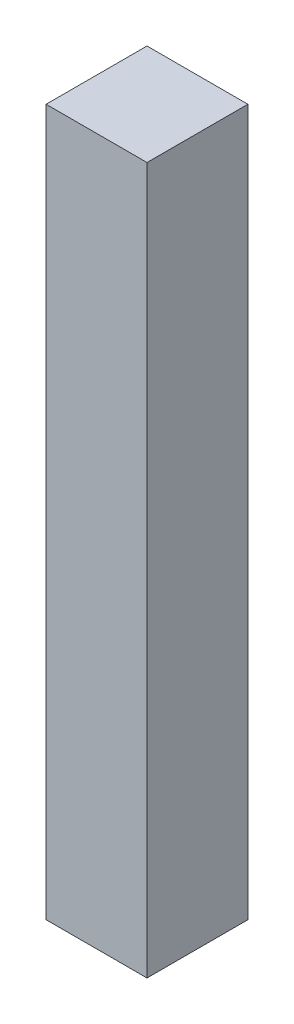
from build123d import *

# Parameters (mm, degrees)
ESQUISSE1_W        = 50
ESQUISSE1_H        = 50
BOSS_EXTRU_1_DEPTH = 350


with BuildPart() as part:
    # Esquisse1 → Boss.-Extru.1 (new body)
    with BuildSketch(Plane(origin=(0, 0, 0), x_dir=(1, 0, 0), z_dir=(0, 1, 0))):
        Rectangle(ESQUISSE1_W, ESQUISSE1_H)
    extrude(amount=BOSS_EXTRU_1_DEPTH)


solid = part.part
